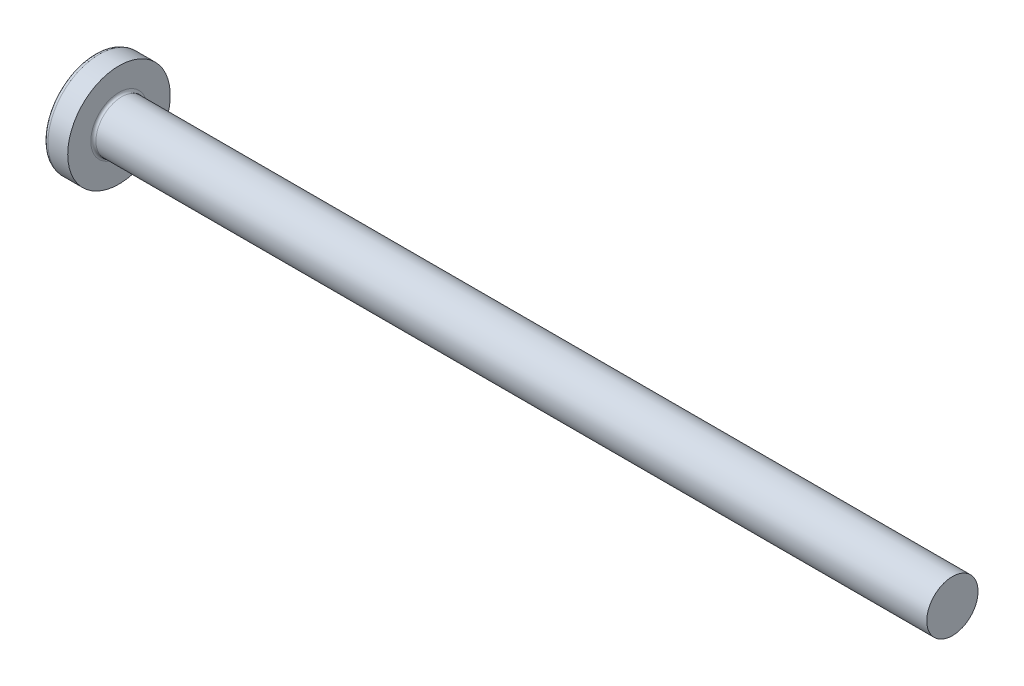
from build123d import *

# Parameters (mm, degrees)
FILLET1_R    = 0.2
SKETCH3_W    = 1.03
SKETCH3_H    = 4.3
SKETCH4_W    = 1.03
SKETCH4_H    = 1.966638464
RECPAT_COUNT = 2
RECPAT_ANGLE = 90


with BuildPart() as part:
    # BodySke → Base-Revolve (revolve)
    with BuildSketch(Plane.XY):
        with BuildLine():
            Line((3.1, 2), (3.1, 4))
            Line((3.1, 4), (1.555305874, 4))
            ThreePointArc((1.555305874, 4), (1.392873227, 3.961271902), (1.265388955, 3.853420195))
            ThreePointArc((1.265388955, 3.853420195), (0.324444487, 2.027933456), (0, 0))
            Line((0, 0), (68.1, 0))
            Line((68.1, 0), (68.1, 2))
            Line((68.1, 2), (3.1, 2))
        make_face()
    revolve(axis=Axis((-25.4, 0, 0), (1, 0, 0)))

    # Fillet1
    fillet1_edges = [part.edges().sort_by_distance(p)[0] for p in [
        (3.1, -2, 0),
    ]]
    fillet(fillet1_edges, radius=FILLET1_R)

    # Sketch3 → Recess section 0
    with BuildSketch(Plane(origin=(0, 0, 0), x_dir=(0, 0, -1), z_dir=(1, 0, 0))):
        Rectangle(SKETCH3_W, SKETCH3_H)
    # Sketch4 → Recess section 1
    with BuildSketch(Plane(origin=(2.34, 0, 0), x_dir=(0, 0, -1), z_dir=(1, 0, 0))):
        Rectangle(SKETCH4_W, SKETCH4_H)
    recess = loft(mode=Mode.SUBTRACT)

    # RecPat: Recess ×2 about axis
    recpat_axis = Axis((0, 0, 0), (1, 0, 0))
    for i in range(1, RECPAT_COUNT):
        add(recess.rotate(recpat_axis, i * RECPAT_ANGLE / (RECPAT_COUNT - 1)), mode=Mode.SUBTRACT)

    # RecCorSke → RecessCore (revolve, cut)
    with BuildSketch(Plane.XY):
        Polygon((0, 0), (0, 1.01462874), (2.34, 0.851), (2.616506661, 0), align=None)
    revolve(axis=Axis((-3.175, 0, 0), (1, 0, 0)), mode=Mode.SUBTRACT)


solid = part.part
